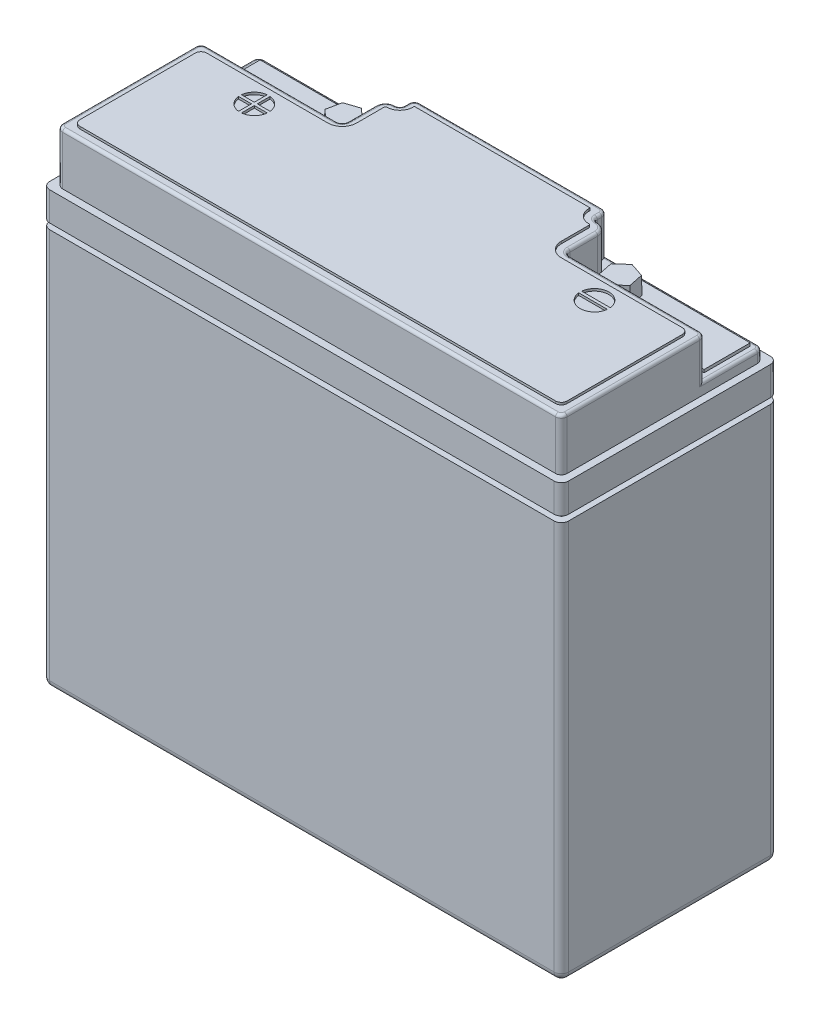
from build123d import *

# Parameters (mm, degrees)
SKETCH1_W                  = 180
SKETCH1_H                  = 150
BATTERY_BODY_DEPTH         = 75
BATTERY_BODY_FILLET_R      = 2.5
BATTERY_TOP_DEPTH          = 18
SKETCH3_W                  = 180
SKETCH3_H                  = 75
SKETCH3_W_2                = 175
SKETCH3_H_2                = 70
BATTERY_BODY_GROVE_DEPTH   = 2
SKETCH4_OUTSIDE_W          = 233.478
SKETCH4_OUTSIDE_H          = 128.478
TERMINAL_CUT_OUTS_DEPTH    = 14
TOP_FILLET_R               = 1
TERMINAL_FILLET_R          = 1
TERMINAL_FILLET_2_R        = 1
SKETCH5_W                  = 45
SKETCH5_H                  = 16
SKETCH5_R                  = 4.5
TERMINAL_PAD_DEPTH         = 1
TOP_TERMINAL_MARKING_DEPTH = 0.8
SKETCH7_W                  = 45
SKETCH7_H                  = 16
SKETCH7_R                  = 4.5
TERMINAL_PAD_2_DEPTH       = 1
TERMINALS_DEPTH            = 6
TERMINALS_TAPER            = 1


with BuildPart() as part:
    # Sketch1 → Battery Body (new body)
    with BuildSketch(Plane.XY):
        with Locations((90, 75)):
            Rectangle(SKETCH1_W, SKETCH1_H)
    extrude(amount=-BATTERY_BODY_DEPTH)

    # Battery Body Fillet
    battery_body_fillet_edges = [part.edges().sort_by_distance(p)[0] for p in [
        (180, 75, -75),
        (0, 75, -75),
        (180, 75, 0),
        (90, 0, 0),
        (0, 75, 0),
        (90, 0, -75),
        (180, 0, -37.5),
        (0, 0, -37.5),
    ]]
    fillet(battery_body_fillet_edges, radius=BATTERY_BODY_FILLET_R)

    # Sketch2 → Battery Top (add)
    with BuildSketch(Plane(origin=(0, 150, 0), x_dir=(-1, 0, 0), z_dir=(0, 1, 0))):
        with BuildLine():
            Line((-4.5, -2.5), (-175.5, -2.5))
            ThreePointArc((-175.5, -2.5), (-176.914213562, -3.085786438), (-177.5, -4.5))
            Line((-177.5, -4.5), (-177.5, -70.5))
            ThreePointArc((-177.5, -70.5), (-176.914213562, -71.914213562), (-175.5, -72.5))
            Line((-175.5, -72.5), (-4.5, -72.5))
            ThreePointArc((-4.5, -72.5), (-3.085786438, -71.914213562), (-2.5, -70.5))
            Line((-2.5, -70.5), (-2.5, -4.5))
            ThreePointArc((-2.5, -4.5), (-3.085786438, -3.085786438), (-4.5, -2.5))
        make_face()
    extrude(amount=BATTERY_TOP_DEPTH)

    # Sketch3 → Battery Body Grove (cut)
    with BuildSketch(Plane.XZ.offset(-140)):
        with Locations((90, -37.5)):
            Rectangle(SKETCH3_W, SKETCH3_H)
        with Locations((90, -37.5)):
            Rectangle(SKETCH3_W_2, SKETCH3_H_2, mode=Mode.SUBTRACT)
    extrude(amount=BATTERY_BODY_GROVE_DEPTH, mode=Mode.SUBTRACT)

    # Sketch4 outside → Terminal Cut-outs (cut)
    with BuildSketch(Plane(origin=(0, 168, 0), x_dir=(-1, 0, 0), z_dir=(0, 1, 0))):
        with Locations((-90, -37.5)):
            Rectangle(SKETCH4_OUTSIDE_W, SKETCH4_OUTSIDE_H)
        with BuildLine():
            Line((-4.5, -52.5), (-49.5, -52.5))
            ThreePointArc((-49.5, -52.5), (-50.914213562, -53.085786438), (-51.5, -54.5))
            Line((-51.5, -54.5), (-51.5, -64.1))
            ThreePointArc((-51.5, -64.1), (-52.495836944, -66.504163056), (-54.9, -67.5))
            Line((-54.9, -67.5), (-55, -67.5))
            ThreePointArc((-55, -67.5), (-56.060660172, -67.939339828), (-56.5, -69))
            Line((-56.5, -69), (-56.5, -70.5))
            ThreePointArc((-56.5, -70.5), (-57.085786438, -71.914213562), (-58.5, -72.5))
            Line((-58.5, -72.5), (-121.5, -72.5))
            ThreePointArc((-121.5, -72.5), (-122.914213562, -71.914213562), (-123.5, -70.5))
            Line((-123.5, -70.5), (-123.5, -69))
            ThreePointArc((-123.5, -69), (-123.939339828, -67.939339828), (-125, -67.5))
            Line((-125, -67.5), (-125.1, -67.5))
            ThreePointArc((-125.1, -67.5), (-127.504163056, -66.504163056), (-128.5, -64.1))
            Line((-128.5, -64.1), (-128.5, -54.5))
            ThreePointArc((-128.5, -54.5), (-129.085786438, -53.085786438), (-130.5, -52.5))
            Line((-130.5, -52.5), (-175.5, -52.5))
            ThreePointArc((-175.5, -52.5), (-176.914213562, -51.914213562), (-177.5, -50.5))
            Line((-177.5, -50.5), (-177.5, -4.5))
            ThreePointArc((-177.5, -4.5), (-176.914213562, -3.085786438), (-175.5, -2.5))
            Line((-175.5, -2.5), (-4.5, -2.5))
            ThreePointArc((-4.5, -2.5), (-3.085786438, -3.085786438), (-2.5, -4.5))
            Line((-2.5, -4.5), (-2.5, -50.5))
            ThreePointArc((-2.5, -50.5), (-3.085786438, -51.914213562), (-4.5, -52.5))
        make_face(mode=Mode.SUBTRACT)
    extrude(amount=-TERMINAL_CUT_OUTS_DEPTH, mode=Mode.SUBTRACT)

    # Top Fillet
    top_fillet_edges = [part.edges().sort_by_distance(p)[0] for p in [
        (90, 168, -72.5),
        (2.5, 168, -27.5),
        (3.085786438, 168, -51.914213562),
        (27, 168, -52.5),
        (50.914213562, 168, -53.085786438),
        (51.5, 168, -59.3),
        (52.495836944, 168, -66.504163056),
        (54.95, 168, -67.5),
        (56.060660172, 168, -67.939339828),
        (56.5, 168, -69.75),
        (57.085786438, 168, -71.914213562),
        (122.914213562, 168, -71.914213562),
        (123.5, 168, -69.75),
        (123.939339828, 168, -67.939339828),
        (125.05, 168, -67.5),
        (127.504163056, 168, -66.504163056),
        (128.5, 168, -59.3),
        (129.085786438, 168, -53.085786438),
        (153, 168, -52.5),
        (176.914213562, 168, -51.914213562),
        (3.085786438, 168, -3.085786438),
        (90, 168, -2.5),
        (176.914213562, 168, -3.085786438),
        (177.5, 168, -27.5),
    ]]
    fillet(top_fillet_edges, radius=TOP_FILLET_R)

    # Terminal Fillet
    terminal_fillet_edges = [part.edges().sort_by_distance(p)[0] for p in [
        (31.5, 154, -72.5),
        (3.085786438, 154, -71.914213562),
        (2.5, 154, -60.5),
    ]]
    fillet(terminal_fillet_edges, radius=TERMINAL_FILLET_R)

    # Terminal Fillet 2
    terminal_fillet_2_edges = [part.edges().sort_by_distance(p)[0] for p in [
        (177.5, 154, -60.5),
        (176.914213562, 154, -71.914213562),
        (148.5, 154, -72.5),
    ]]
    fillet(terminal_fillet_2_edges, radius=TERMINAL_FILLET_2_R)

    # Sketch5 → Terminal Pad (add)
    with BuildSketch(Plane(origin=(0, 154, 0), x_dir=(-1, 0, 0), z_dir=(0, 1, 0))):
        with Locations((-27.5, -62.5)):
            Rectangle(SKETCH5_W, SKETCH5_H)
        with Locations((-42, -62.5)):
            Circle(SKETCH5_R, mode=Mode.SUBTRACT)
    extrude(amount=TERMINAL_PAD_DEPTH)

    # Sketch6 → Top terminal Marking (add)
    with BuildSketch(Plane(origin=(0, 168, 0), x_dir=(-1, 0, 0), z_dir=(0, 1, 0))):
        with BuildLine():
            ThreePointArc((-5.5, -7.5), (-6.085786438, -6.085786438), (-7.5, -5.5))
            Line((-7.5, -5.5), (-172.5, -5.5))
            ThreePointArc((-172.5, -5.5), (-173.914213562, -6.085786438), (-174.5, -7.5))
            Line((-174.5, -7.5), (-174.5, -47.5))
            ThreePointArc((-174.5, -47.5), (-173.914213562, -48.914213562), (-172.5, -49.5))
            Line((-172.5, -49.5), (-130.5, -49.5))
            ThreePointArc((-130.5, -49.5), (-126.964466094, -50.964466094), (-125.5, -54.5))
            Line((-125.5, -54.5), (-125.5, -64.1))
            ThreePointArc((-125.5, -64.1), (-125.382842712, -64.382842712), (-125.1, -64.5))
            Line((-125.1, -64.5), (-125, -64.5))
            ThreePointArc((-125, -64.5), (-121.818019485, -65.818019485), (-120.5, -69))
            Line((-120.5, -69), (-120.5, -69.5))
            Line((-120.5, -69.5), (-59.5, -69.5))
            Line((-59.5, -69.5), (-59.5, -69))
            ThreePointArc((-59.5, -69), (-58.181980515, -65.818019485), (-55, -64.5))
            Line((-55, -64.5), (-54.9, -64.5))
            ThreePointArc((-54.9, -64.5), (-54.617157288, -64.382842712), (-54.5, -64.1))
            Line((-54.5, -64.1), (-54.5, -54.5))
            ThreePointArc((-54.5, -54.5), (-53.035533906, -50.964466094), (-49.5, -49.5))
            Line((-49.5, -49.5), (-7.5, -49.5))
            ThreePointArc((-7.5, -49.5), (-6.085786438, -48.914213562), (-5.5, -47.5))
            Line((-5.5, -47.5), (-5.5, -7.5))
        make_face()
        with BuildLine():
            Line((-153.974937186, -43), (-144.025062814, -43))
            ThreePointArc((-144.025062814, -43), (-149, -47.5), (-153.974937186, -43))
        make_face(mode=Mode.SUBTRACT)
        with BuildLine():
            ThreePointArc((-153.974937186, -42), (-149, -37.5), (-144.025062814, -42))
            Line((-144.025062814, -42), (-153.974937186, -42))
        make_face(mode=Mode.SUBTRACT)
        with BuildLine():
            Line((-31.5, -43), (-31.5, -47.474937186))
            ThreePointArc((-31.5, -47.474937186), (-34.535533906, -46.035533906), (-35.974937186, -43))
            Line((-35.974937186, -43), (-31.5, -43))
        make_face(mode=Mode.SUBTRACT)
        with BuildLine():
            ThreePointArc((-26.025062814, -43), (-27.464466094, -46.035533906), (-30.5, -47.474937186))
            Line((-30.5, -47.474937186), (-30.5, -43))
            Line((-30.5, -43), (-26.025062814, -43))
        make_face(mode=Mode.SUBTRACT)
        with BuildLine():
            Line((-31.5, -37.525062814), (-31.5, -42))
            Line((-31.5, -42), (-35.974937186, -42))
            ThreePointArc((-35.974937186, -42), (-34.535533906, -38.964466094), (-31.5, -37.525062814))
        make_face(mode=Mode.SUBTRACT)
        with BuildLine():
            Line((-26.025062814, -42), (-30.5, -42))
            Line((-30.5, -42), (-30.5, -37.525062814))
            ThreePointArc((-30.5, -37.525062814), (-27.464466094, -38.964466094), (-26.025062814, -42))
        make_face(mode=Mode.SUBTRACT)
    extrude(amount=TOP_TERMINAL_MARKING_DEPTH)

    # Sketch7 → Terminal Pad 2 (add)
    with BuildSketch(Plane(origin=(0, 154, 0), x_dir=(-1, 0, 0), z_dir=(0, 1, 0))):
        with Locations((-152.5, -62.5)):
            Rectangle(SKETCH7_W, SKETCH7_H)
        with Locations((-138, -62.5)):
            Circle(SKETCH7_R, mode=Mode.SUBTRACT)
    extrude(amount=TERMINAL_PAD_2_DEPTH)

    # Sketch9 → Terminals (add)
    with BuildSketch(Plane(origin=(0, 155, 0), x_dir=(-1, 0, 0), z_dir=(0, 1, 0))):
        Polygon((-36.977946953, -60.829242867), (-40.935891597, -57.315395915), (-45.957944645, -58.986153048), (-47.022053047, -64.170757133), (-43.064108403, -67.684604085), (-38.042055355, -66.013846952), align=None)
        Polygon((-141.957944645, -66.013846952), (-136.935891597, -67.684604085), (-132.977946953, -64.170757133), (-134.042055355, -58.986153048), (-139.064108403, -57.315395915), (-143.022053047, -60.829242867), align=None)
    extrude(amount=TERMINALS_DEPTH, taper=TERMINALS_TAPER)


solid = part.part
